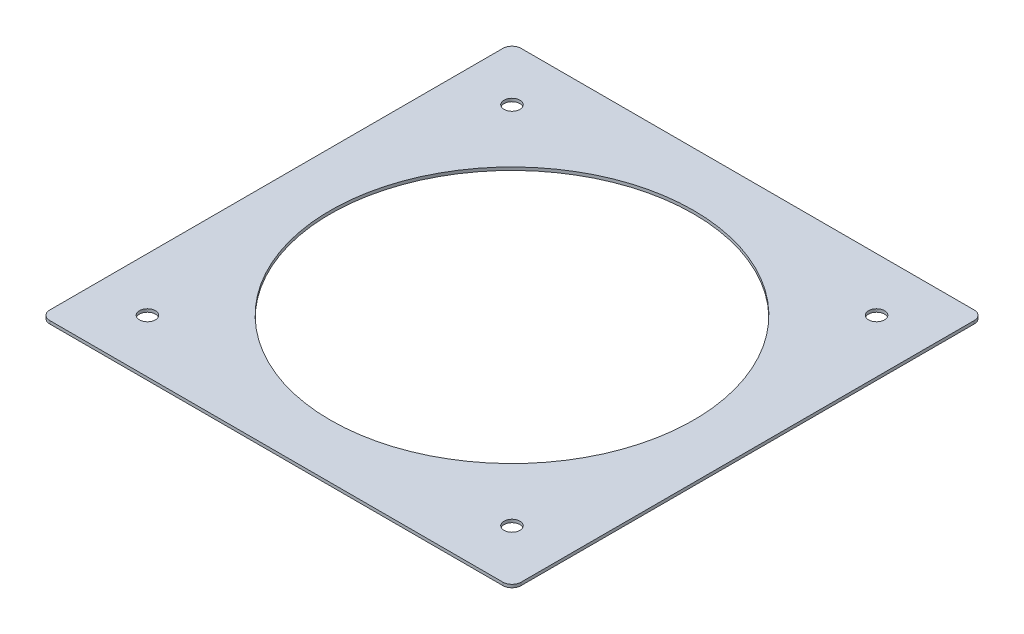
from build123d import *

# Parameters (mm, degrees)
SKETCH1_R           = 60
SKETCH1_R_2         = 2.637642313
BOSS_EXTRUDE1_DEPTH = 1


with BuildPart() as part:
    # Sketch1 → Boss-Extrude1 (new body)
    with BuildSketch(Plane(origin=(0, 0, 0), x_dir=(1, 0, 0), z_dir=(0, 1, 0))):
        with BuildLine():
            Line((77.459067431, -74.053128544), (77.459067431, 75.622473214))
            ThreePointArc((77.459067431, 75.622473214), (76.57640363, 77.753412133), (74.445464711, 78.636075934))
            Line((74.445464711, 78.636075934), (-75.230137046, 78.636075934))
            ThreePointArc((-75.230137046, 78.636075934), (-77.361075965, 77.753412133), (-78.243739766, 75.622473214))
            Line((-78.243739766, 75.622473214), (-78.243739766, -74.053128544))
            ThreePointArc((-78.243739766, -74.053128544), (-77.361075965, -76.184067463), (-75.230137046, -77.066731264))
            Line((-75.230137046, -77.066731264), (74.445464711, -77.066731264))
            ThreePointArc((74.445464711, -77.066731264), (76.57640363, -76.184067463), (77.459067431, -74.053128544))
        make_face()
        with Locations((-0.392336167, 0.784672335)):
            Circle(SKETCH1_R, mode=Mode.SUBTRACT)
        with Locations((-60.606097453, -59.429088951)):
            Circle(SKETCH1_R_2, mode=Mode.SUBTRACT)
        with Locations((-60.606097453, 60.998433621)):
            Circle(SKETCH1_R_2, mode=Mode.SUBTRACT)
        with Locations((59.821425118, -59.429088951)):
            Circle(SKETCH1_R_2, mode=Mode.SUBTRACT)
        with Locations((59.821425118, 60.998433621)):
            Circle(SKETCH1_R_2, mode=Mode.SUBTRACT)
    extrude(amount=BOSS_EXTRUDE1_DEPTH)


solid = part.part
